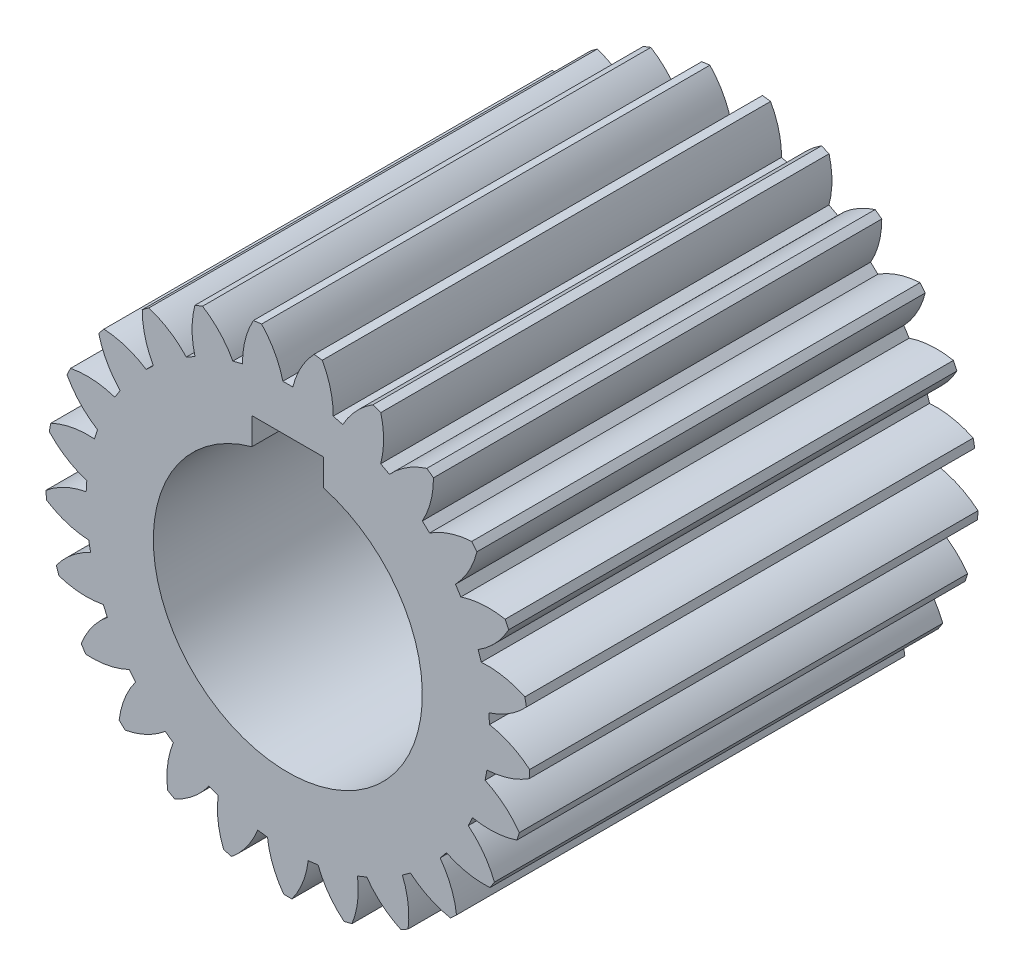
from build123d import *

# Parameters (mm, degrees)
SKETCH1_R           = 27
BOSS_EXTRUDE1_DEPTH = 50
CUT_EXTRUDE1_DEPTH  = 50
CIRPATTERN1_COUNT   = 25
CUT_EXTRUDE2_DEPTH  = 50


with BuildPart() as part:
    # Sketch1 → Boss-Extrude1 (new body)
    with BuildSketch(Plane.XY):
        Circle(SKETCH1_R)
    extrude(amount=BOSS_EXTRUDE1_DEPTH)

    # Sketch3 → Cut-Extrude1 (cut)
    with BuildSketch(Plane.XY.offset(50)):
        with BuildLine():
            Line((3.082235405, 27), (-3.082235405, 27))
            ThreePointArc((-3.082235405, 27), (-1.513981077, 24.920996669), (-0.55457938, 22.5))
            Line((-0.55457938, 22.5), (0.55457938, 22.5))
            ThreePointArc((0.55457938, 22.5), (1.513981077, 24.920996669), (3.082235405, 27))
        make_face()
    cut_extrude1 = extrude(amount=-CUT_EXTRUDE1_DEPTH, mode=Mode.SUBTRACT)

    # CirPattern1: Cut-Extrude1 ×25 about axis
    cirpattern1_axis = Axis((0, 0, 0), (0, 0, 1))
    for i in range(1, CIRPATTERN1_COUNT):
        add(cut_extrude1.rotate(cirpattern1_axis, i * 360 / CIRPATTERN1_COUNT), mode=Mode.SUBTRACT)

    # Sketch4 → Cut-Extrude2 (cut)
    with BuildSketch(Plane.XY.offset(50)):
        with BuildLine():
            Line((-4, 14.456832295), (-4, 17.456832295))
            Line((-4, 17.456832295), (4, 17.456832295))
            Line((4, 17.456832295), (4, 14.456832295))
            ThreePointArc((4, 14.456832295), (0, -15), (-4, 14.456832295))
        make_face()
    extrude(amount=-CUT_EXTRUDE2_DEPTH, mode=Mode.SUBTRACT)


solid = part.part
